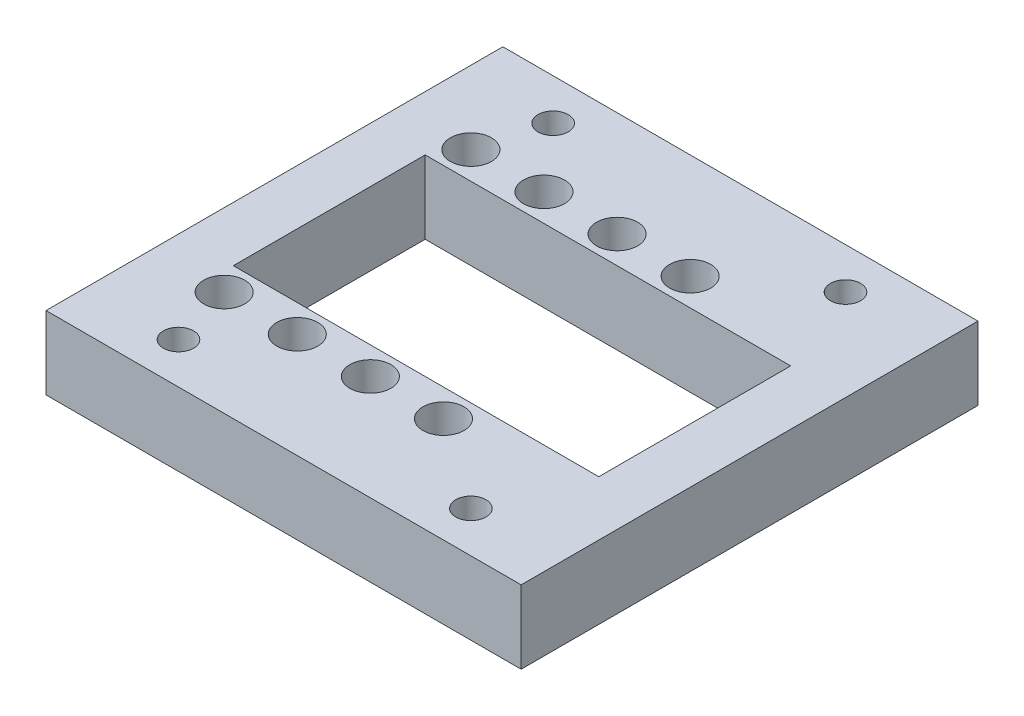
from build123d import *

# Parameters (mm, degrees)
SKETCH1_W           = 52
SKETCH1_H           = 50
SKETCH1_R           = 1.125
SKETCH1_R_2         = 1.65
SKETCH1_W_2         = 40
SKETCH1_H_2         = 21
BOSS_EXTRUDE1_DEPTH = 8
SKETCH2_R           = 2.25
SKETCH2_R_2         = 1.125
CUT_EXTRUDE1_DEPTH  = 3.5


with BuildPart() as part:
    # Sketch1 → Boss-Extrude1 (new body)
    with BuildSketch(Plane(origin=(0, 0, 0), x_dir=(1, 0, 0), z_dir=(0, 1, 0))):
        with Locations((18, 0)):
            Rectangle(SKETCH1_W, SKETCH1_H)
        with Locations((0, 13.5)):
            Circle(SKETCH1_R, mode=Mode.SUBTRACT)
        with Locations((8, 13.5)):
            Circle(SKETCH1_R, mode=Mode.SUBTRACT)
        with Locations((16, 13.5)):
            Circle(SKETCH1_R, mode=Mode.SUBTRACT)
        with Locations((24, 13.5)):
            Circle(SKETCH1_R, mode=Mode.SUBTRACT)
        with Locations((24, -13.5)):
            Circle(SKETCH1_R, mode=Mode.SUBTRACT)
        with Locations((16, -13.5)):
            Circle(SKETCH1_R, mode=Mode.SUBTRACT)
        with Locations((8, -13.5)):
            Circle(SKETCH1_R, mode=Mode.SUBTRACT)
        with Locations((0, -13.5)):
            Circle(SKETCH1_R, mode=Mode.SUBTRACT)
        with Locations((34, 20.5)):
            Circle(SKETCH1_R_2, mode=Mode.SUBTRACT)
        with Locations((2, 20.5)):
            Circle(SKETCH1_R_2, mode=Mode.SUBTRACT)
        with Locations((34, -20.5)):
            Circle(SKETCH1_R_2, mode=Mode.SUBTRACT)
        with Locations((2, -20.5)):
            Circle(SKETCH1_R_2, mode=Mode.SUBTRACT)
        with Locations((18, 0)):
            Rectangle(SKETCH1_W_2, SKETCH1_H_2, mode=Mode.SUBTRACT)
    extrude(amount=BOSS_EXTRUDE1_DEPTH)

    # Sketch2 → Cut-Extrude1 (cut)
    with BuildSketch(Plane(origin=(0, 8, 0), x_dir=(1, 0, 0), z_dir=(0, 1, 0))):
        with Locations((0, 13.5)):
            Circle(SKETCH2_R)
        with Locations((0, 13.5)):
            Circle(SKETCH2_R_2, mode=Mode.SUBTRACT)
        with Locations((8, 13.5)):
            Circle(SKETCH2_R)
        with Locations((8, 13.5)):
            Circle(SKETCH2_R_2, mode=Mode.SUBTRACT)
        with Locations((16, 13.5)):
            Circle(SKETCH2_R)
        with Locations((16, 13.5)):
            Circle(SKETCH2_R_2, mode=Mode.SUBTRACT)
        with Locations((24, 13.5)):
            Circle(SKETCH2_R)
        with Locations((24, 13.5)):
            Circle(SKETCH2_R_2, mode=Mode.SUBTRACT)
        with Locations((24, -13.5)):
            Circle(SKETCH2_R)
        with Locations((24, -13.5)):
            Circle(SKETCH2_R_2, mode=Mode.SUBTRACT)
        with Locations((16, -13.5)):
            Circle(SKETCH2_R)
        with Locations((16, -13.5)):
            Circle(SKETCH2_R_2, mode=Mode.SUBTRACT)
        with Locations((8, -13.5)):
            Circle(SKETCH2_R)
        with Locations((8, -13.5)):
            Circle(SKETCH2_R_2, mode=Mode.SUBTRACT)
        with Locations((0, -13.5)):
            Circle(SKETCH2_R)
        with Locations((0, -13.5)):
            Circle(SKETCH2_R_2, mode=Mode.SUBTRACT)
    extrude(amount=-CUT_EXTRUDE1_DEPTH, mode=Mode.SUBTRACT)


solid = part.part
